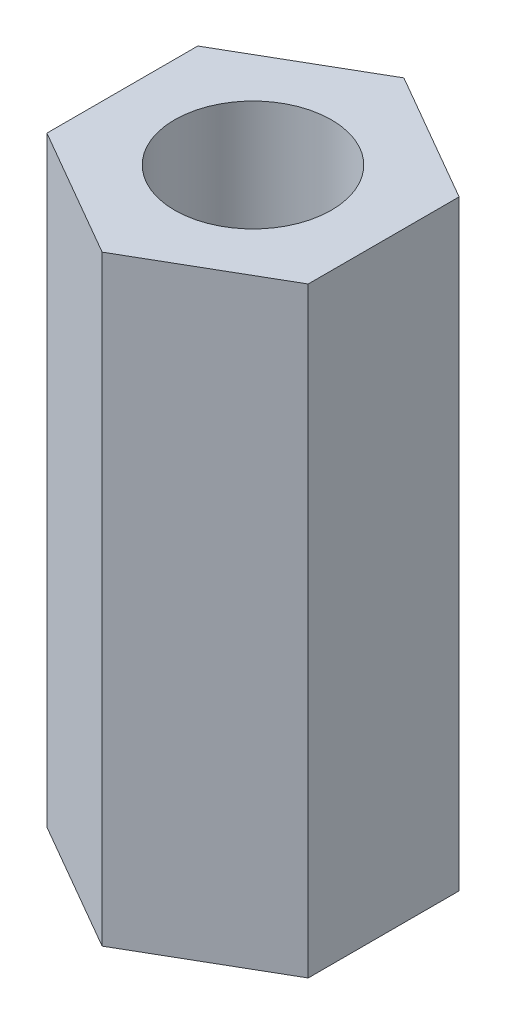
from build123d import *

# Parameters (mm, degrees)
SKETCH_1_R      = 1.5
EXTRUDE_1_DEPTH = 11.5


with BuildPart() as part:
    # Эскиз1 → Бобышка-Вытянуть1 (new body)
    with BuildSketch(Plane(origin=(0, 0, 0), x_dir=(1, 0, 0), z_dir=(0, 1, 0))):
        Polygon((0, -2.886751346), (2.5, -1.443375673), (2.5, 1.443375673), (0, 2.886751346), (-2.5, 1.443375673), (-2.5, -1.443375673), align=None)
        Circle(SKETCH_1_R, mode=Mode.SUBTRACT)
    extrude(amount=EXTRUDE_1_DEPTH)


solid = part.part
